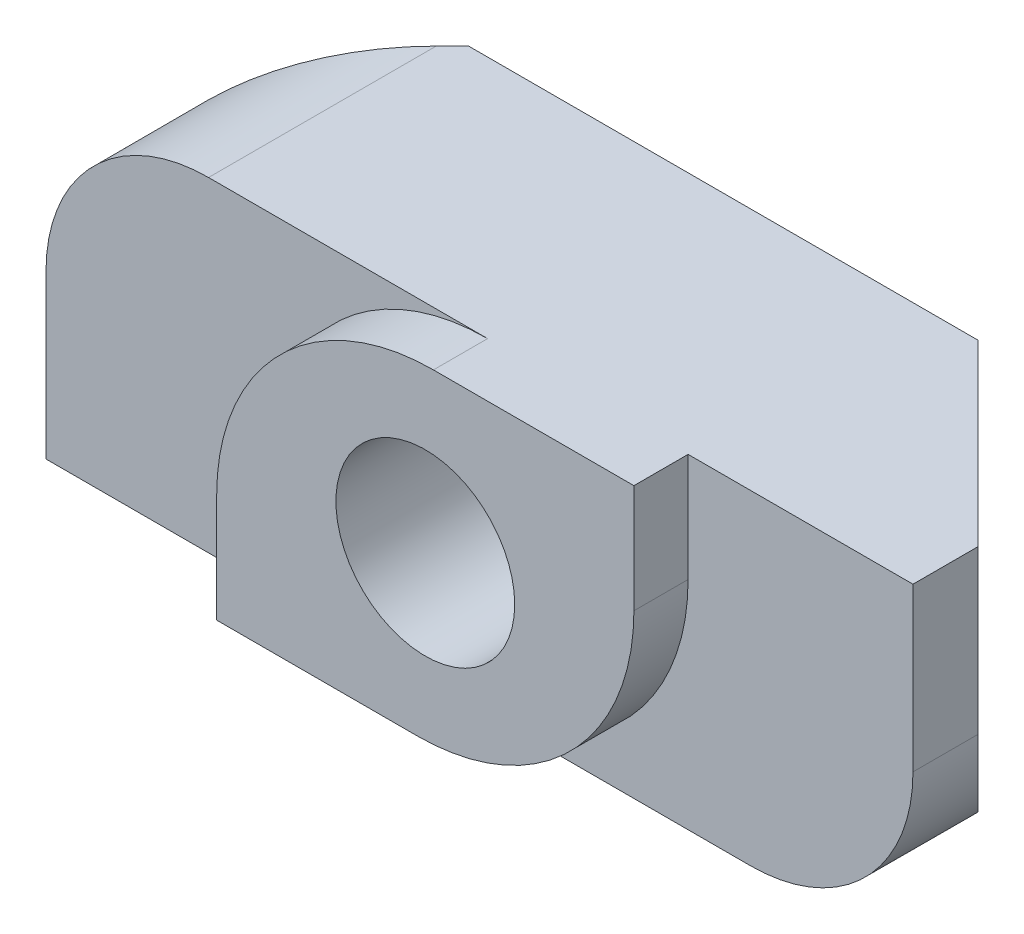
from build123d import *

# Parameters (mm, degrees)
BOSS_EXTRUDE1_DEPTH = 6
SKETCH2_R           = 1.65
CUT_EXTRUDE1_DEPTH  = 6.5
FILLET1_R           = 4
FILLET2_R           = 3


with BuildPart() as part:
    # Sketch1 → Boss-Extrude1 (new body)
    with BuildSketch(Plane(origin=(0, 0, 0), x_dir=(1, 0, 0), z_dir=(0, 1, 0))):
        Polygon((4.7, 0), (-4.7, 0), (-8, -3.3), (-8, -4.5), (-3.85, -4.5), (-3.85, -5.5), (3.85, -5.5), (3.85, -4.5), (8, -4.5), (8, -3.3), align=None)
    extrude(amount=BOSS_EXTRUDE1_DEPTH)

    # Sketch2 → Cut-Extrude1 (cut, through all)
    with BuildSketch(Plane.XY.offset(5.5)):
        with Locations((0, 3)):
            Circle(SKETCH2_R)
    extrude(amount=-CUT_EXTRUDE1_DEPTH, mode=Mode.SUBTRACT)

    # Fillet1
    fillet1_edges = [part.edges().sort_by_distance(p)[0] for p in [
        (3.85, 0, 5),
        (-3.85, 6, 5),
    ]]
    fillet(fillet1_edges, radius=FILLET1_R)

    # Fillet2
    fillet2_edges = [part.edges().sort_by_distance(p)[0] for p in [
        (8, 0, 3.9),
        (-8, 6, 3.9),
    ]]
    fillet(fillet2_edges, radius=FILLET2_R)


solid = part.part
